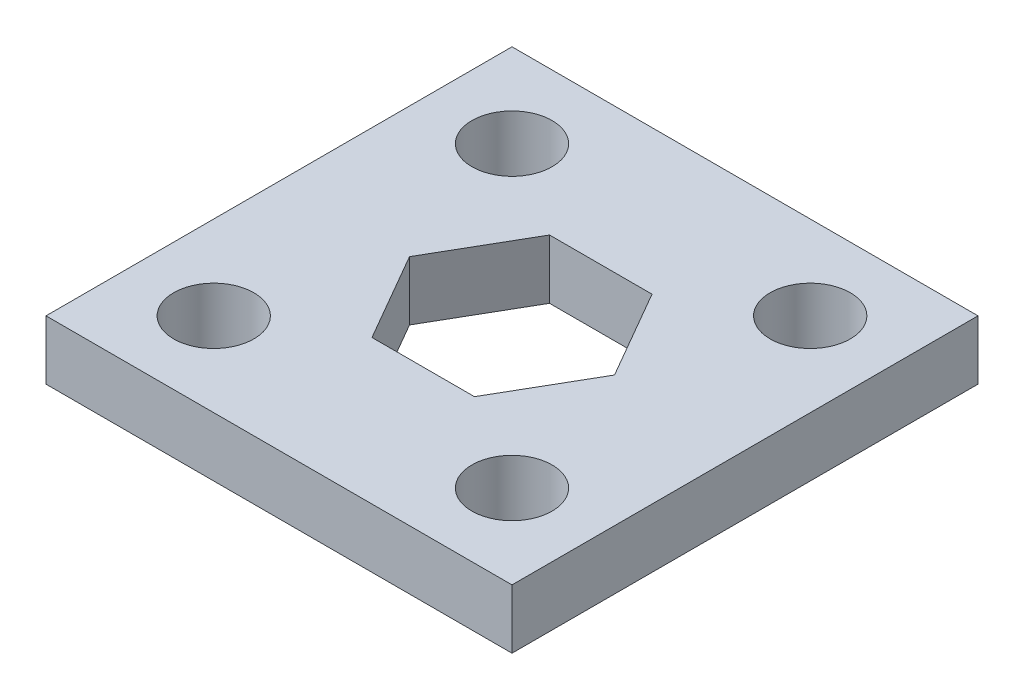
from build123d import *

# Parameters (mm, degrees)
SKETCH1_W           = 25
SKETCH1_H           = 25
SKETCH1_R           = 2.15
BOSS_EXTRUDE1_DEPTH = 1.5875


with BuildPart() as part:
    # Sketch1 → Boss-Extrude1 (new body, symmetric)
    with BuildSketch(Plane(origin=(0, 0, 0), x_dir=(1, 0, 0), z_dir=(0, 1, 0))):
        Rectangle(SKETCH1_W, SKETCH1_H)
        with Locations((-8, 8)):
            Circle(SKETCH1_R, mode=Mode.SUBTRACT)
        with Locations((8, 8)):
            Circle(SKETCH1_R, mode=Mode.SUBTRACT)
        with Locations((8, -8)):
            Circle(SKETCH1_R, mode=Mode.SUBTRACT)
        with Locations((-8, -8)):
            Circle(SKETCH1_R, mode=Mode.SUBTRACT)
        Polygon((-2.749630657, -4.7625), (2.749630657, -4.7625), (5.499261314, 0), (2.749630657, 4.7625), (-2.749630657, 4.7625), (-5.499261314, 0), align=None, mode=Mode.SUBTRACT)
    extrude(amount=BOSS_EXTRUDE1_DEPTH, both=True)


solid = part.part
